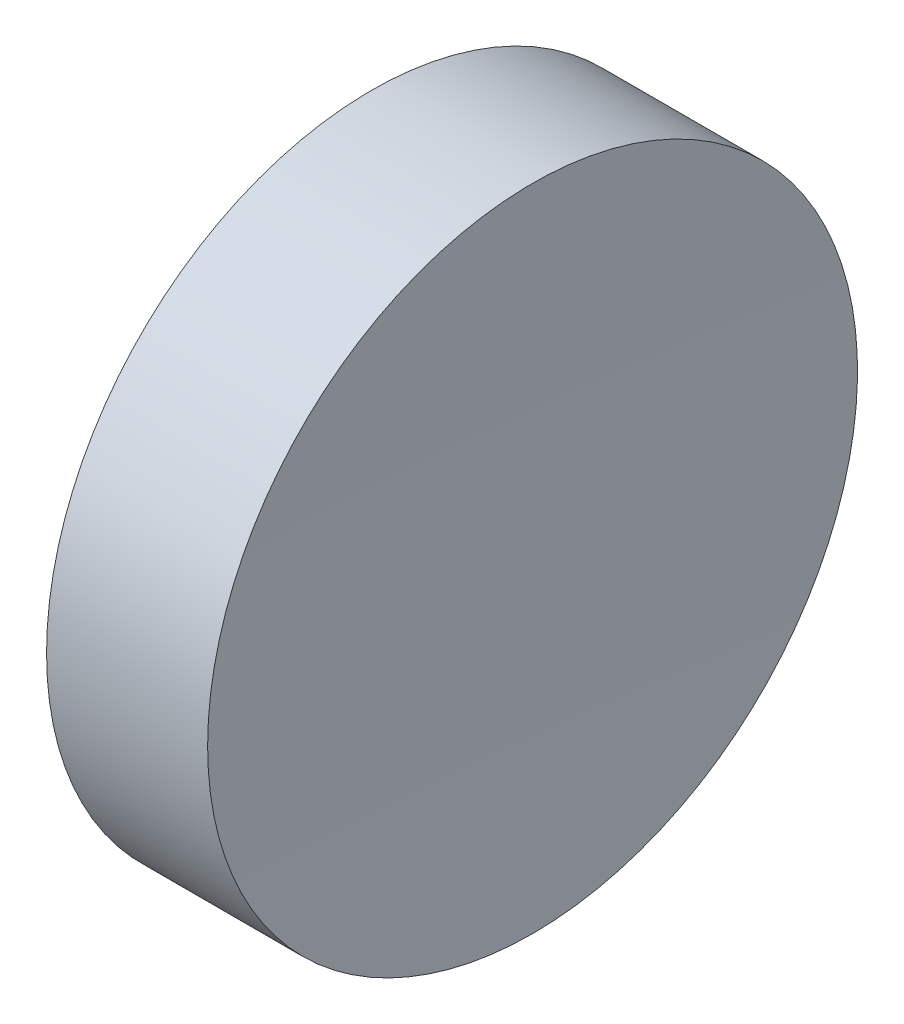
from build123d import *


with BuildPart() as part:
    # 草图1 → 旋转1 (revolve)
    with BuildSketch(Plane.XY, mode=Mode.PRIVATE) as revolve_1_sk:
        with BuildLine():
            Line((115.092655535, 69.378021123), (115.092655535, 81.878021123))
            Line((115.092655535, 81.878021123), (121.288015747, 81.878021123))
            ThreePointArc((121.288015747, 81.878021123), (121.141498574, 75.628784389), (121.09265554, 69.378021123))
            Line((121.09265554, 69.378021123), (115.092655535, 69.378021123))
        make_face()
    revolve(revolve_1_sk.sketch.rotate(Axis((108.985143002, 69.378021123, 0), (1, 0, 0)), 180), axis=Axis((108.985143002, 69.378021123, 0), (1, 0, 0)))  # turned: the seam where the file's is


solid = part.part
